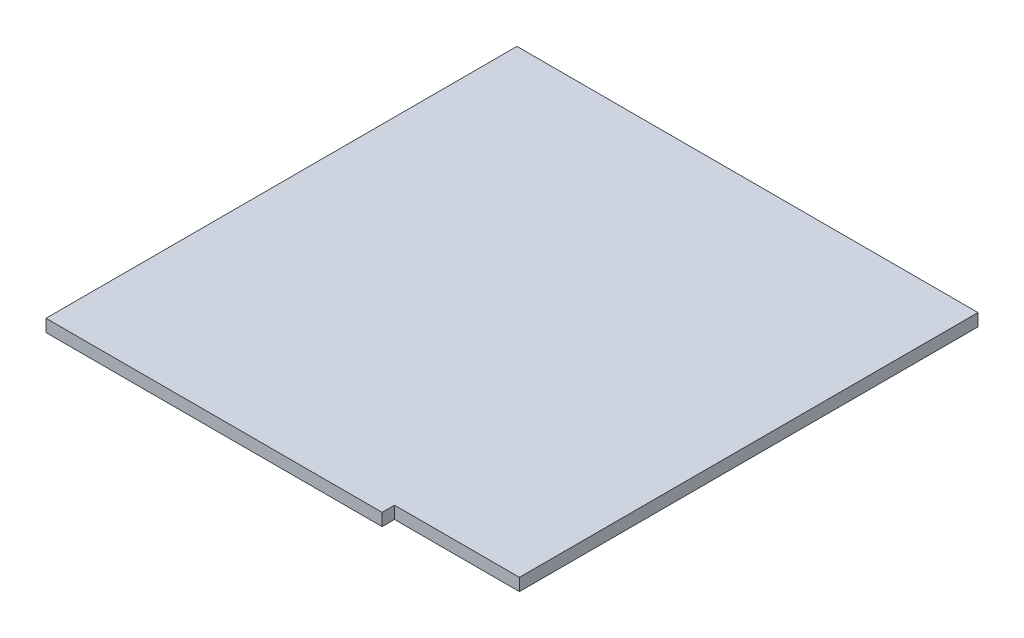
from build123d import *

# Parameters (mm, degrees)
BOSS_EXTRUDE1_DEPTH = 15.875


with BuildPart() as part:
    # Sketch1 → Boss-Extrude1 (new body)
    with BuildSketch(Plane(origin=(0, 0, 0), x_dir=(1, 0, 0), z_dir=(0, 1, 0))):
        Polygon((430.53, 0), (430.53, 15.875), (590.55, 15.875), (590.55, 603.25), (0, 603.25), (0, 0), align=None)
    extrude(amount=BOSS_EXTRUDE1_DEPTH)


solid = part.part
